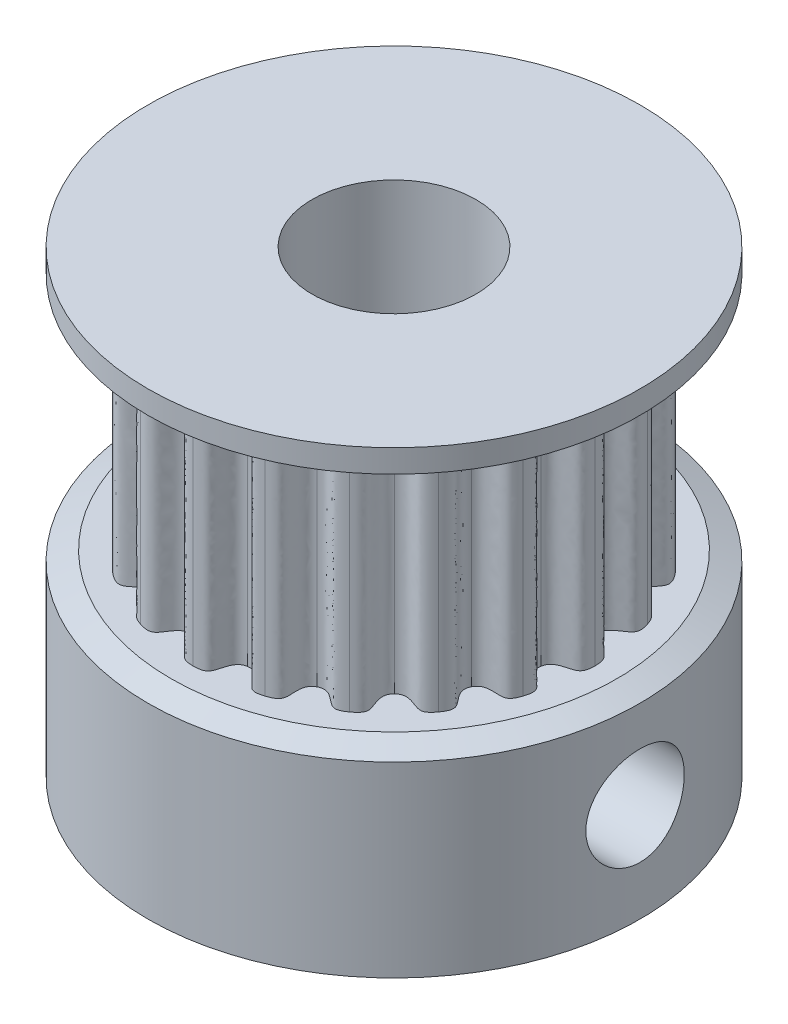
from build123d import *

# Parameters (mm, degrees)
SKETCH1_R           = 7.5
BOSS_EXTRUDE1_DEPTH = 6
BOSS_EXTRUDE2_DEPTH = 7
SKETCH3_R           = 7.5
BOSS_EXTRUDE3_DEPTH = 1
CHAMFER1_SIZE       = 0.7
CHAMFER1_SIZE2      = 0.3
CHAMFER2_SIZE       = 0.3
CHAMFER2_SIZE2      = 0.7
SKETCH4_R           = 2.5
CUT_EXTRUDE1_DEPTH  = 15
SKETCH5_R           = 1.5
CUT_EXTRUDE2_DEPTH  = 8.5
SKETCH6_R           = 1.5
CUT_EXTRUDE3_DEPTH  = 8.5000001


with BuildPart() as part:
    # Sketch1 → Boss-Extrude1 (new body)
    with BuildSketch(Plane(origin=(0, 0, 0), x_dir=(1, 0, 0), z_dir=(0, 1, 0))):
        Circle(SKETCH1_R)
    extrude(amount=BOSS_EXTRUDE1_DEPTH)

    # Sketch2 → Boss-Extrude2 (add)
    with BuildSketch(Plane(origin=(0, 6, 0), x_dir=(1, 0, 0), z_dir=(0, 1, 0))):
        with BuildLine():
            add(Edge.make_bspline(
                [(-1.893492512, 5.827570733), (-1.625029431, 5.914799676), (-1.358701977, 5.799242859), (-1.173307285, 5.258205424), (-0.848512146, 5.310105079)],
                knots=[0, 0, 0, 0, 0.37473965, 1, 1, 1, 1], degree=3))
            add(Edge.make_bspline(
                [(0, 6.127470485), (-0.288048954, 6.126679624), (-0.521591646, 5.945599185), (-0.520553502, 5.359355868), (-0.848512146, 5.310105079)],
                knots=[0, 0, 0, 0, 0.382401283, 1, 1, 1, 1], degree=3))
            add(Edge.make_bspline(
                [(0, 6.127470485), (0.345787572, 6.127470485), (0.436122161, 5.934324912), (0.547453343, 5.357793239), (0.841221719, 5.3112649)],
                knots=[0, 0, 0, 0, 0.372906977, 1, 1, 1, 1], degree=3))
            add(Edge.make_bspline(
                [(1.893492512, 5.827570733), (1.564628989, 5.934424969), (1.419030425, 5.778647536), (1.134990094, 5.26473656), (0.841221719, 5.3112649)],
                knots=[0, 0, 0, 0, 0.372906977, 1, 1, 1, 1], degree=3))
            add(Edge.make_bspline(
                [(1.893492512, 5.827570733), (2.161955594, 5.74034179), (2.309496437, 5.490311012), (2.141470068, 4.943630267), (2.434740708, 4.794708177)],
                knots=[0, 0, 0, 0, 0.37473965, 1, 1, 1, 1], degree=3))
            add(Edge.make_bspline(
                [(3.601636785, 4.957227755), (3.36813543, 5.125898862), (3.072759011, 5.11667466), (2.729013712, 4.641783647), (2.434740708, 4.794708177)],
                knots=[0, 0, 0, 0, 0.382401283, 1, 1, 1, 1], degree=3))
            add(Edge.make_bspline(
                [(3.601636785, 4.957227755), (3.830005122, 4.791308446), (3.893061043, 4.507922417), (3.564324829, 4.039921136), (3.797222325, 3.8076622)],
                knots=[0, 0, 0, 0, 0.37473965, 1, 1, 1, 1], degree=3))
            add(Edge.make_bspline(
                [(4.957227755, 3.601636785), (4.787277008, 3.834208428), (4.503506905, 3.916712023), (4.029836305, 3.57128697), (3.797222325, 3.8076622)],
                knots=[0, 0, 0, 0, 0.382401283, 1, 1, 1, 1], degree=3))
            add(Edge.make_bspline(
                [(4.957227755, 3.601636785), (5.123147064, 3.373268448), (5.09554571, 3.084266967), (4.638278642, 2.740756376), (4.788005365, 2.447895717)],
                knots=[0, 0, 0, 0, 0.37473965, 1, 1, 1, 1], degree=3))
            add(Edge.make_bspline(
                [(5.827570733, 1.893492512), (5.737806558, 2.167198958), (5.493420166, 2.333354323), (4.936190443, 2.151207842), (4.788005365, 2.447895717)],
                knots=[0, 0, 0, 0, 0.382401283, 1, 1, 1, 1], degree=3))
            add(Edge.make_bspline(
                [(5.827570733, 1.893492512), (5.914799676, 1.625029431), (5.799242859, 1.358701977), (5.258205424, 1.173307285), (5.310105079, 0.848512146)],
                knots=[0, 0, 0, 0, 0.37473965, 1, 1, 1, 1], degree=3))
            add(Edge.make_bspline(
                [(6.127470485, 0), (6.126679624, 0.288048954), (5.945599185, 0.521591646), (5.359355868, 0.520553502), (5.310105079, 0.848512146)],
                knots=[0, 0, 0, 0, 0.382401283, 1, 1, 1, 1], degree=3))
            add(Edge.make_bspline(
                [(6.127470485, 0), (6.127470485, -0.282278789), (5.935269712, -0.499862229), (5.363422424, -0.508993297), (5.312414711, -0.833929706)],
                knots=[0, 0, 0, 0, 0.37473965, 1, 1, 1, 1], degree=3))
            add(Edge.make_bspline(
                [(5.827570733, -1.893492512), (5.915830602, -1.619297288), (5.815781531, -1.341228056), (5.2579102, -1.161056242), (5.312414711, -0.833929706)],
                knots=[0, 0, 0, 0, 0.382401283, 1, 1, 1, 1], degree=3))
            add(Edge.make_bspline(
                [(5.827570733, -1.893492512), (5.74034179, -2.161955594), (5.490311012, -2.309496437), (4.943630267, -2.141470068), (4.794708177, -2.434740708)],
                knots=[0, 0, 0, 0, 0.37473965, 1, 1, 1, 1], degree=3))
            add(Edge.make_bspline(
                [(4.957227755, -3.601636785), (5.125898862, -3.36813543), (5.11667466, -3.072759011), (4.641783647, -2.729013712), (4.794708177, -2.434740708)],
                knots=[0, 0, 0, 0, 0.382401283, 1, 1, 1, 1], degree=3))
            add(Edge.make_bspline(
                [(4.957227755, -3.601636785), (4.791308446, -3.830005122), (4.507922417, -3.893061043), (4.039921136, -3.564324829), (3.8076622, -3.797222325)],
                knots=[0, 0, 0, 0, 0.37473965, 1, 1, 1, 1], degree=3))
            add(Edge.make_bspline(
                [(3.601636785, -4.957227755), (3.834208428, -4.787277008), (3.916712023, -4.503506905), (3.57128697, -4.029836305), (3.8076622, -3.797222325)],
                knots=[0, 0, 0, 0, 0.382401283, 1, 1, 1, 1], degree=3))
            add(Edge.make_bspline(
                [(3.601636785, -4.957227755), (3.373268448, -5.123147064), (3.084266967, -5.09554571), (2.740756376, -4.638278642), (2.447895717, -4.788005365)],
                knots=[0, 0, 0, 0, 0.37473965, 1, 1, 1, 1], degree=3))
            add(Edge.make_bspline(
                [(1.893492512, -5.827570733), (2.167198958, -5.737806558), (2.333354323, -5.493420166), (2.151207842, -4.936190443), (2.447895717, -4.788005365)],
                knots=[0, 0, 0, 0, 0.382401283, 1, 1, 1, 1], degree=3))
            add(Edge.make_bspline(
                [(1.893492512, -5.827570733), (1.625029431, -5.914799676), (1.358701977, -5.799242859), (1.173307285, -5.258205424), (0.848512146, -5.310105079)],
                knots=[0, 0, 0, 0, 0.37473965, 1, 1, 1, 1], degree=3))
            add(Edge.make_bspline(
                [(0, -6.127470485), (0.288048954, -6.126679624), (0.521591646, -5.945599185), (0.520553502, -5.359355868), (0.848512146, -5.310105079)],
                knots=[0, 0, 0, 0, 0.382401283, 1, 1, 1, 1], degree=3))
            add(Edge.make_bspline(
                [(0, -6.127470485), (-0.282278789, -6.127470485), (-0.499862229, -5.935269712), (-0.508993297, -5.363422424), (-0.833929706, -5.312414711)],
                knots=[0, 0, 0, 0, 0.37473965, 1, 1, 1, 1], degree=3))
            add(Edge.make_bspline(
                [(-1.893492512, -5.827570733), (-1.619297288, -5.915830602), (-1.341228056, -5.815781531), (-1.161056242, -5.2579102), (-0.833929706, -5.312414711)],
                knots=[0, 0, 0, 0, 0.382401283, 1, 1, 1, 1], degree=3))
            add(Edge.make_bspline(
                [(-1.893492512, -5.827570733), (-2.161955594, -5.74034179), (-2.309496437, -5.490311012), (-2.141470068, -4.943630267), (-2.434740708, -4.794708177)],
                knots=[0, 0, 0, 0, 0.37473965, 1, 1, 1, 1], degree=3))
            add(Edge.make_bspline(
                [(-3.601636785, -4.957227755), (-3.36813543, -5.125898862), (-3.072759011, -5.11667466), (-2.729013712, -4.641783647), (-2.434740708, -4.794708177)],
                knots=[0, 0, 0, 0, 0.382401283, 1, 1, 1, 1], degree=3))
            add(Edge.make_bspline(
                [(-3.601636785, -4.957227755), (-3.830005122, -4.791308446), (-3.893061043, -4.507922417), (-3.564324829, -4.039921136), (-3.797222325, -3.8076622)],
                knots=[0, 0, 0, 0, 0.37473965, 1, 1, 1, 1], degree=3))
            add(Edge.make_bspline(
                [(-4.957227755, -3.601636785), (-4.787277008, -3.834208428), (-4.503506905, -3.916712023), (-4.029836305, -3.57128697), (-3.797222325, -3.8076622)],
                knots=[0, 0, 0, 0, 0.382401283, 1, 1, 1, 1], degree=3))
            add(Edge.make_bspline(
                [(-4.957227755, -3.601636785), (-5.123147064, -3.373268448), (-5.09554571, -3.084266967), (-4.638278642, -2.740756376), (-4.788005365, -2.447895717)],
                knots=[0, 0, 0, 0, 0.37473965, 1, 1, 1, 1], degree=3))
            add(Edge.make_bspline(
                [(-5.827570733, -1.893492512), (-5.737806558, -2.167198958), (-5.493420166, -2.333354323), (-4.936190443, -2.151207842), (-4.788005365, -2.447895717)],
                knots=[0, 0, 0, 0, 0.382401283, 1, 1, 1, 1], degree=3))
            add(Edge.make_bspline(
                [(-5.827570733, -1.893492512), (-5.914799676, -1.625029431), (-5.799242859, -1.358701977), (-5.258205424, -1.173307285), (-5.310105079, -0.848512146)],
                knots=[0, 0, 0, 0, 0.37473965, 1, 1, 1, 1], degree=3))
            add(Edge.make_bspline(
                [(-6.127470485, 0), (-6.126679624, -0.288048954), (-5.945599185, -0.521591646), (-5.359355868, -0.520553502), (-5.310105079, -0.848512146)],
                knots=[0, 0, 0, 0, 0.382401283, 1, 1, 1, 1], degree=3))
            add(Edge.make_bspline(
                [(-6.127470485, 0), (-6.127470485, 0.282278789), (-5.935269712, 0.499862229), (-5.363422424, 0.508993297), (-5.312414711, 0.833929706)],
                knots=[0, 0, 0, 0, 0.37473965, 1, 1, 1, 1], degree=3))
            add(Edge.make_bspline(
                [(-5.827570733, 1.893492512), (-5.915830602, 1.619297288), (-5.815781531, 1.341228056), (-5.2579102, 1.161056242), (-5.312414711, 0.833929706)],
                knots=[0, 0, 0, 0, 0.382401283, 1, 1, 1, 1], degree=3))
            add(Edge.make_bspline(
                [(-5.827570733, 1.893492512), (-5.74034179, 2.161955594), (-5.490311012, 2.309496437), (-4.943630267, 2.141470068), (-4.794708177, 2.434740708)],
                knots=[0, 0, 0, 0, 0.37473965, 1, 1, 1, 1], degree=3))
            add(Edge.make_bspline(
                [(-4.957227755, 3.601636785), (-5.125898862, 3.36813543), (-5.11667466, 3.072759011), (-4.641783647, 2.729013712), (-4.794708177, 2.434740708)],
                knots=[0, 0, 0, 0, 0.382401283, 1, 1, 1, 1], degree=3))
            add(Edge.make_bspline(
                [(-4.957227755, 3.601636785), (-4.791308446, 3.830005122), (-4.507922417, 3.893061043), (-4.039921136, 3.564324829), (-3.8076622, 3.797222325)],
                knots=[0, 0, 0, 0, 0.37473965, 1, 1, 1, 1], degree=3))
            add(Edge.make_bspline(
                [(-3.601636785, 4.957227755), (-3.834208428, 4.787277008), (-3.916712023, 4.503506905), (-3.57128697, 4.029836305), (-3.8076622, 3.797222325)],
                knots=[0, 0, 0, 0, 0.382401283, 1, 1, 1, 1], degree=3))
            add(Edge.make_bspline(
                [(-3.601636785, 4.957227755), (-3.373268448, 5.123147064), (-3.084266967, 5.09554571), (-2.740756376, 4.638278642), (-2.447895717, 4.788005365)],
                knots=[0, 0, 0, 0, 0.37473965, 1, 1, 1, 1], degree=3))
            add(Edge.make_bspline(
                [(-1.893492512, 5.827570733), (-2.167198958, 5.737806558), (-2.333354323, 5.493420166), (-2.151207842, 4.936190443), (-2.447895717, 4.788005365)],
                knots=[0, 0, 0, 0, 0.382401283, 1, 1, 1, 1], degree=3))
        make_face()
    extrude(amount=BOSS_EXTRUDE2_DEPTH)

    # Sketch3 → Boss-Extrude3 (add)
    with BuildSketch(Plane(origin=(0, 13, 0), x_dir=(1, 0, 0), z_dir=(0, 1, 0))):
        Circle(SKETCH3_R)
    extrude(amount=BOSS_EXTRUDE3_DEPTH)

    # Chamfer1
    chamfer1_edges = [part.edges().sort_by_distance(p)[0] for p in [
        (-7.5, 13, 0),
    ]]
    chamfer1_side = [part.faces().sort_by_distance(p)[0] for p in [
        (-7.287867963, 13, 0),
    ]]
    chamfer(chamfer1_edges, length=CHAMFER1_SIZE, length2=CHAMFER1_SIZE2, reference=chamfer1_side[0])

    # Chamfer2
    chamfer2_edges = [part.edges().sort_by_distance(p)[0] for p in [
        (-7.5, 6, 0),
    ]]
    chamfer2_side = [part.faces().sort_by_distance(p)[0] for p in [
        (-7.5, 3, 0),
    ]]
    chamfer(chamfer2_edges, length=CHAMFER2_SIZE, length2=CHAMFER2_SIZE2, reference=chamfer2_side[0])

    # Sketch4 → Cut-Extrude1 (cut, through all)
    with BuildSketch(Plane.XZ):
        Circle(SKETCH4_R)
    extrude(amount=-CUT_EXTRUDE1_DEPTH, mode=Mode.SUBTRACT)

    # Sketch5 → Cut-Extrude2 (cut, through all)
    with BuildSketch(Plane(origin=(0, 0, 0), x_dir=(0, 0, -1), z_dir=(1, 0, 0))):
        with Locations((0, 3)):
            Circle(SKETCH5_R)
    extrude(amount=CUT_EXTRUDE2_DEPTH, mode=Mode.SUBTRACT)

    # Sketch6 → Cut-Extrude3 (cut, through all)
    with BuildSketch(Plane.XY):
        with Locations((0, 3)):
            Circle(SKETCH6_R)
    extrude(amount=-CUT_EXTRUDE3_DEPTH, mode=Mode.SUBTRACT)


solid = part.part
